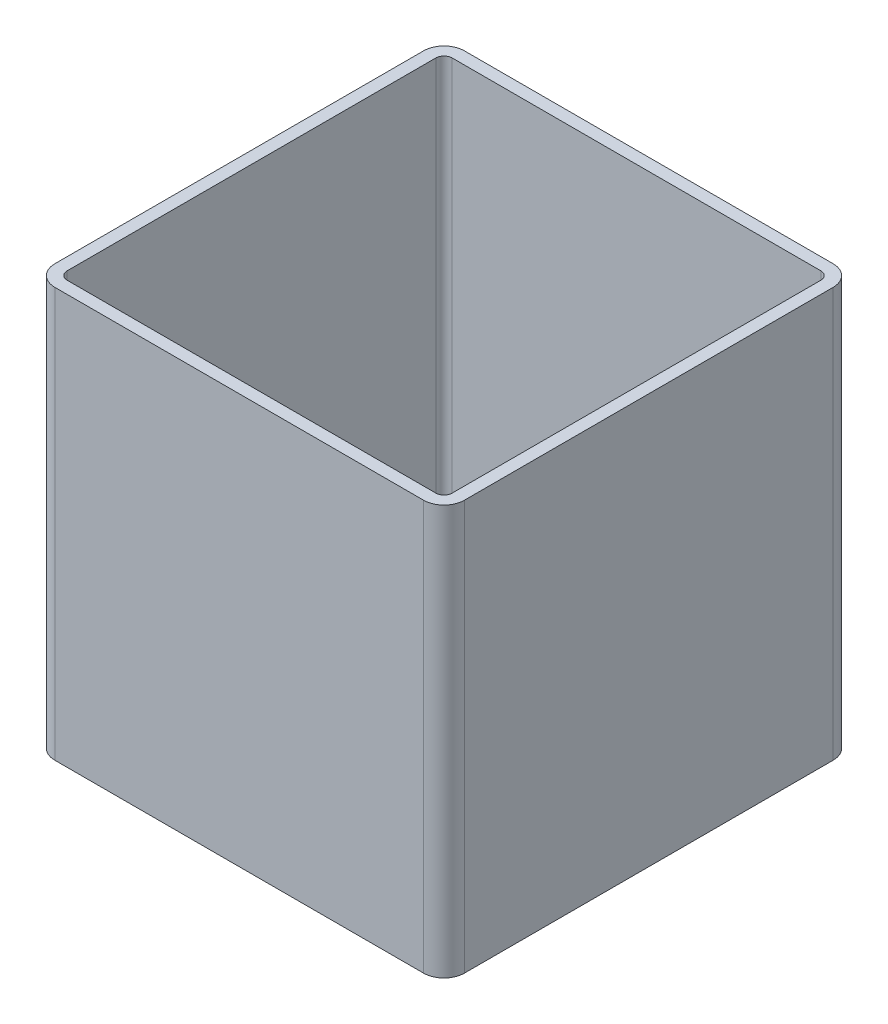
from build123d import *

# Parameters (mm, degrees)
EXTRUDE_1_DEPTH = 100


with BuildPart() as part:
    # Эскиз1 → Вытянуть-Тонкостенный1 (new body)
    with BuildSketch(Plane(origin=(0, 0, 0), x_dir=(1, 0, 0), z_dir=(0, 1, 0))):
        with BuildLine():
            Line((-45, 50), (45, 50))
            ThreePointArc((45, 50), (48.535533906, 48.535533906), (50, 45))
            Line((50, 45), (50, -45))
            ThreePointArc((50, -45), (48.535533906, -48.535533906), (45, -50))
            Line((45, -50), (-45, -50))
            ThreePointArc((-45, -50), (-48.535533906, -48.535533906), (-50, -45))
            Line((-50, -45), (-50, 45))
            ThreePointArc((-50, 45), (-48.535533906, 48.535533906), (-45, 50))
        make_face()
        with BuildLine():
            Line((-45, 47), (45, 47))
            ThreePointArc((45, 47), (46.414213562, 46.414213562), (47, 45))
            Line((47, 45), (47, -45))
            ThreePointArc((47, -45), (46.414213562, -46.414213562), (45, -47))
            Line((45, -47), (-45, -47))
            ThreePointArc((-45, -47), (-46.414213562, -46.414213562), (-47, -45))
            Line((-47, -45), (-47, 45))
            ThreePointArc((-47, 45), (-46.414213562, 46.414213562), (-45, 47))
        make_face(mode=Mode.SUBTRACT)
    extrude(amount=EXTRUDE_1_DEPTH)


solid = part.part
